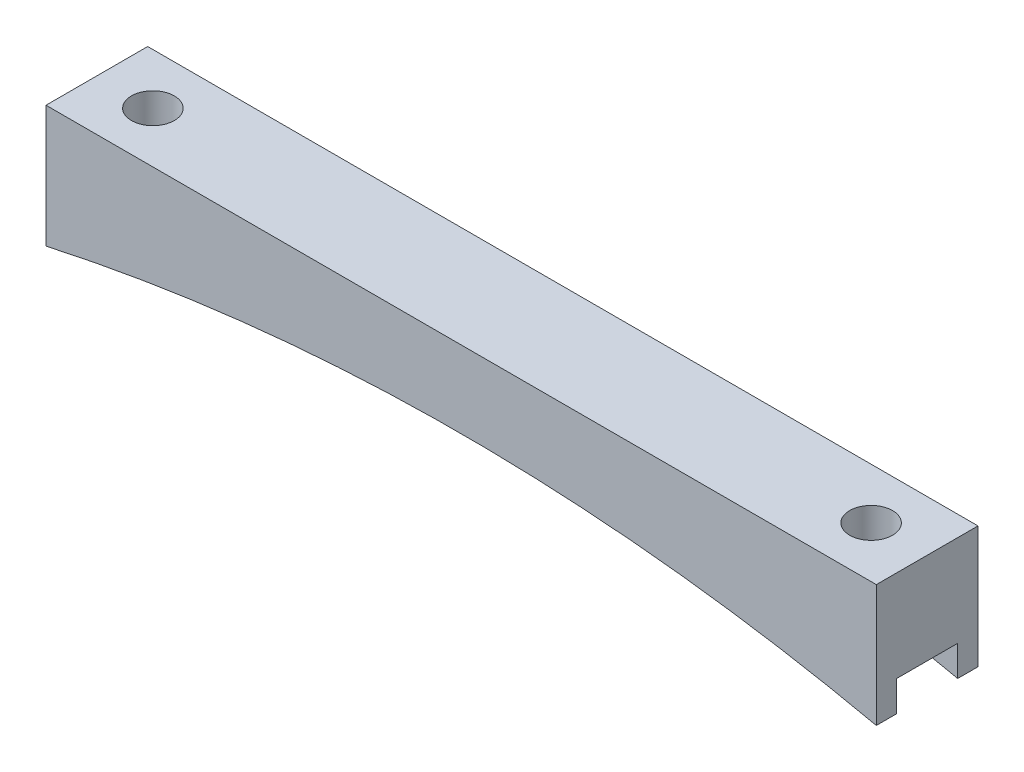
from build123d import *

# Parameters (mm, degrees)
BOSS_EXTRUDE1_DEPTH = 12.7
SKETCH2_R           = 2.675
CUT_EXTRUDE1_DEPTH  = 16.24
SKETCH3_W           = 7.62
SKETCH3_H           = 3.81
CUT_EXTRUDE2_DEPTH  = 104.7100001


with BuildPart() as part:
    # Sketch1 → Boss-Extrude1 (new body)
    with BuildSketch(Plane.XY):
        with BuildLine():
            Line((-51.855, 0), (51.855, 0))
            Line((51.855, 0), (51.855, -15.24))
            ThreePointArc((51.855, -15.24), (0, -9.602362237), (-51.855, -15.24))
            Line((-51.855, -15.24), (-51.855, 0))
        make_face()
    extrude(amount=BOSS_EXTRUDE1_DEPTH)

    # Sketch2 → Cut-Extrude1 (cut, through all)
    with BuildSketch(Plane(origin=(0, 0, 0), x_dir=(1, 0, 0), z_dir=(0, 1, 0))):
        with Locations((-44.855, -6.35)):
            Circle(SKETCH2_R)
        with Locations((44.855, -6.35)):
            Circle(SKETCH2_R)
    extrude(amount=-CUT_EXTRUDE1_DEPTH, mode=Mode.SUBTRACT)

    # Sketch3 → Cut-Extrude2 (cut, through all)
    with BuildSketch(Plane(origin=(51.855, 0, 0), x_dir=(0, 0, -1), z_dir=(1, 0, 0))):
        with Locations((-6.35, -13.335)):
            Rectangle(SKETCH3_W, SKETCH3_H)
    extrude(amount=-CUT_EXTRUDE2_DEPTH, mode=Mode.SUBTRACT)


solid = part.part
